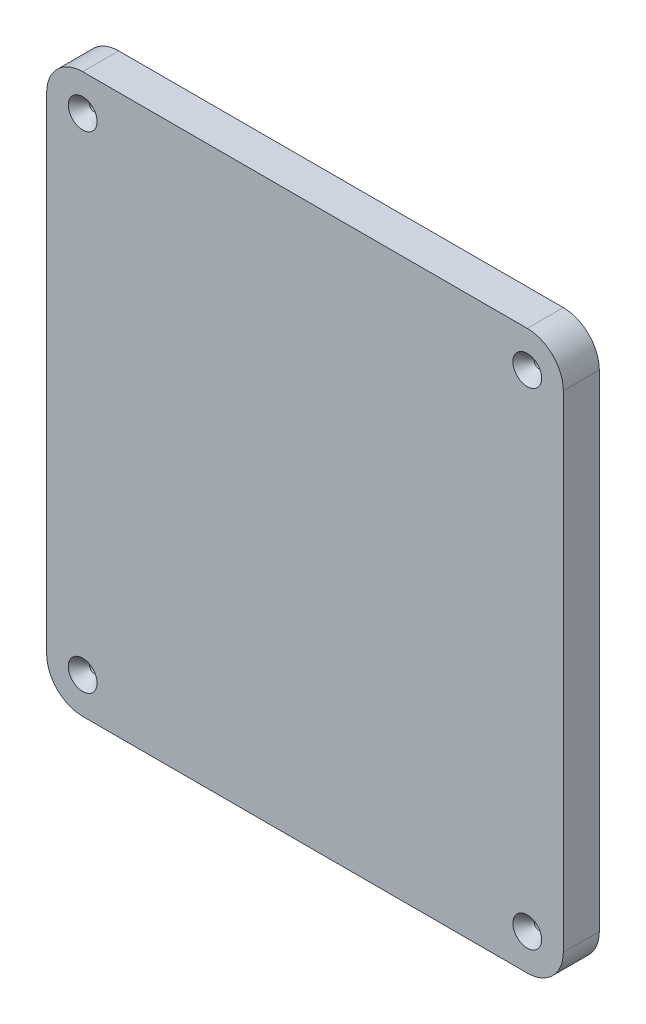
from build123d import *

# Parameters (mm, degrees)
SKETCH1_W           = 182.149999994
SKETCH1_H           = 196.85
BOSS_EXTRUDE1_DEPTH = 12.7
FILLET1_R           = 12.7
HOLE1_D             = 3.175
HOLE1_DEPTH         = 31.75
HOLE1_CSINK_D       = 10.16
HOLE1_CSINK_ANGLE   = 82
HOLE1_TIP           = 0.953866233


with BuildPart() as part:
    # Sketch1 → Boss-Extrude1 (new body)
    with BuildSketch(Plane.XY):
        with Locations((47.975000003, 766.50216301)):
            Rectangle(SKETCH1_W, SKETCH1_H)
    extrude(amount=BOSS_EXTRUDE1_DEPTH)

    # Fillet1
    fillet1_edges = [part.edges().sort_by_distance(p)[0] for p in [
        (-43.099999994, 668.07716301, 6.35),
        (-43.099999994, 864.92716301, 6.35),
        (139.05, 864.92716301, 6.35),
        (139.05, 668.07716301, 6.35),
    ]]
    fillet(fillet1_edges, radius=FILLET1_R)

    # Hole1
    with Locations(Plane(origin=(47.975000003, -457.960607328, 12.7), x_dir=(1, 0, 0), z_dir=(0, 0, 1))):
        with Locations((-78.374999997, 1310.187770337), (-78.374999997, 1138.737770337), (78.374999997, 1138.737770337), (78.374999997, 1310.187770337)):
            CounterSinkHole(HOLE1_D / 2, HOLE1_CSINK_D / 2, depth=HOLE1_DEPTH, counter_sink_angle=HOLE1_CSINK_ANGLE)
            with Locations((0, 0, -(HOLE1_DEPTH + HOLE1_TIP / 2))):  # 118° drill point
                Cone(0, HOLE1_D / 2, HOLE1_TIP, mode=Mode.SUBTRACT)


solid = part.part
